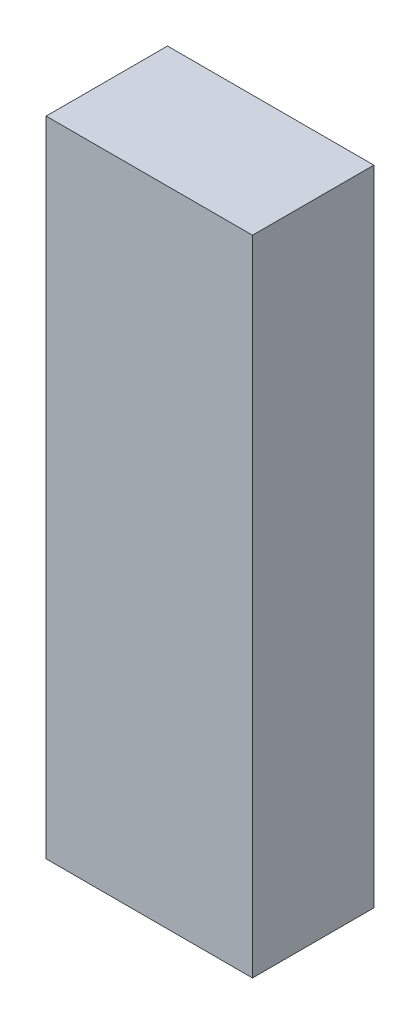
from build123d import *

# Parameters (mm, degrees)
SKETCH1_W           = 34
SKETCH1_H           = 106
BOSS_EXTRUDE1_DEPTH = 20


with BuildPart() as part:
    # Sketch1 → Boss-Extrude1 (new body)
    with BuildSketch(Plane.XY):
        with Locations((17, 53)):
            Rectangle(SKETCH1_W, SKETCH1_H)
    extrude(amount=BOSS_EXTRUDE1_DEPTH)


solid = part.part
